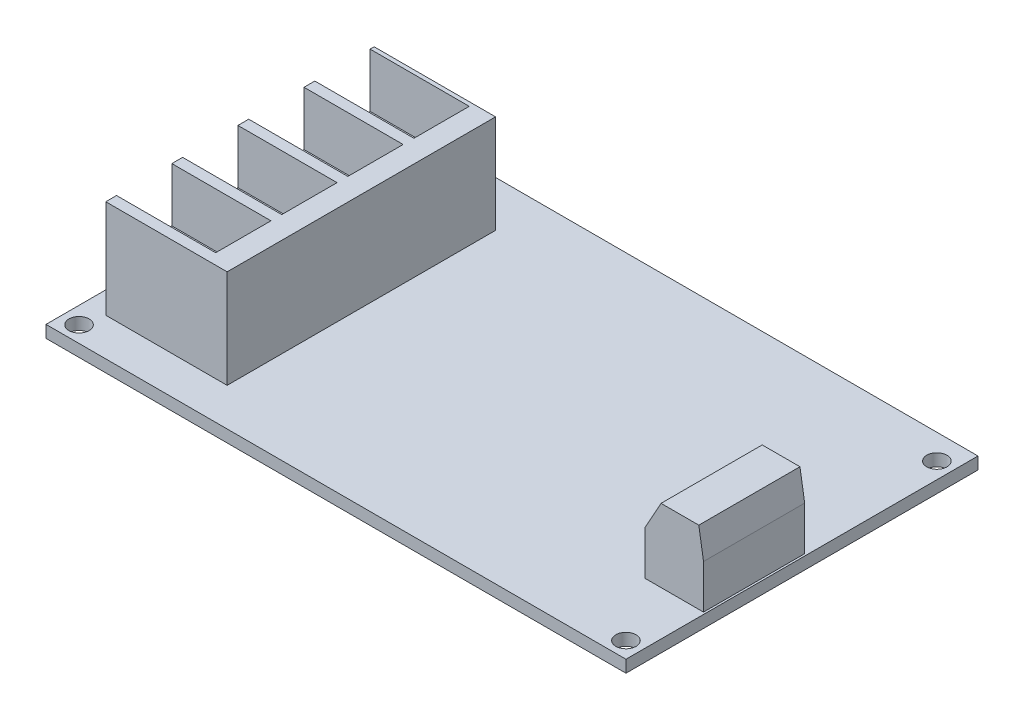
from build123d import *

# Parameters (mm, degrees)
SKETCH1_W           = 86
SKETCH1_H           = 52.2
BOSS_EXTRUDE1_DEPTH = 1.8
SKETCH3_R           = 1.5
CUT_EXTRUDE1_DEPTH  = 1.8
SKETCH4_W           = 8.7
SKETCH4_H           = 15
BOSS_EXTRUDE2_DEPTH = 6.5
SKETCH5_W           = 5.6
SKETCH5_H           = 15
BOSS_EXTRUDE3_DEPTH = 4.32
RIB11_REACH         = 94.939
SKETCH7_WALL_W      = 192.82008193
SKETCH7_WALL_H      = 15
RIB14_REACH         = 94.939
SKETCH8_WALL_W      = 192.25452497
SKETCH8_WALL_H      = 15
SKETCH9_W           = 18
SKETCH9_H           = 39.8
BOSS_EXTRUDE4_DEPTH = 14.58
SKETCH10_W          = 14.7
SKETCH10_H          = 8.2
CUT_EXTRUDE2_DEPTH  = 8


with BuildPart() as part:
    # Sketch1 → Boss-Extrude1 (new body)
    with BuildSketch(Plane(origin=(0, 0, 0), x_dir=(1, 0, 0), z_dir=(0, 1, 0))):
        with Locations((43, 26.1)):
            Rectangle(SKETCH1_W, SKETCH1_H)
    extrude(amount=BOSS_EXTRUDE1_DEPTH)

    # Sketch3 → Cut-Extrude1 (cut)
    with BuildSketch(Plane(origin=(0, 1.8, 0), x_dir=(1, 0, 0), z_dir=(0, 1, 0))):
        with Locations(Location((83.6, 2.4, 0), (0, 0, 270))):
            Circle(SKETCH3_R)
        with Locations(Location((83.6, 48.5, 0), (0, 0, 270))):
            Circle(SKETCH3_R)
        with Locations(Location((2.5, 2.4, 0), (0, 0, 270))):
            Circle(SKETCH3_R)
        with Locations(Location((2.5, 48.5, 0), (0, 0, 270))):
            Circle(SKETCH3_R)
    extrude(amount=-CUT_EXTRUDE1_DEPTH, mode=Mode.SUBTRACT)


with BuildPart() as body_2:
    # Sketch4 → Boss-Extrude2 (new body)
    with BuildSketch(Plane(origin=(0, 1.8, 0), x_dir=(1, 0, 0), z_dir=(0, 1, 0))):
        with Locations((81.35, 19.3)):
            Rectangle(SKETCH4_W, SKETCH4_H)
    extrude(amount=BOSS_EXTRUDE2_DEPTH)

    # Sketch5 → Boss-Extrude3 (add)
    with BuildSketch(Plane(origin=(0, 8.3, 0), x_dir=(1, 0, 0), z_dir=(0, 1, 0))):
        with Locations((82.2, 19.3)):
            Rectangle(SKETCH5_W, SKETCH5_H)
    extrude(amount=BOSS_EXTRUDE3_DEPTH)

    # Sketch7 wall → Rib11 (add, up to next)
    with BuildSketch(Plane(origin=(78.2, 10.46, -19.3), x_dir=(-0.485642931179, -0.874157276122, 0), z_dir=(0.874157276122, -0.485642931179, 0)), mode=Mode.PRIVATE) as rib11_sk1:
        Rectangle(SKETCH7_WALL_W, SKETCH7_WALL_H)
    rib11_tool1 = extrude(rib11_sk1.sketch, amount=RIB11_REACH, mode=Mode.PRIVATE) - body_2.part
    add(rib11_tool1.solids().sort_by_distance((78.2, 10.46, -19.3))[0])

    # Sketch8 wall → Rib14 (add, up to next)
    with BuildSketch(Plane(origin=(85.35, 10.46, -19.3), x_dir=(0.159950808002, -0.987124986524, 0), z_dir=(0.987124986524, 0.159950808002, 0)), mode=Mode.PRIVATE) as rib14_sk1:
        Rectangle(SKETCH8_WALL_W, SKETCH8_WALL_H)
    rib14_tool1 = extrude(rib14_sk1.sketch, amount=-RIB14_REACH, mode=Mode.PRIVATE) - body_2.part
    add(rib14_tool1.solids().sort_by_distance((85.35, 10.46, -19.3))[0])


with BuildPart() as body_3:
    # Sketch9 → Boss-Extrude4 (new body)
    with BuildSketch(Plane(origin=(0, 1.8, 0), x_dir=(1, 0, 0), z_dir=(0, 1, 0))):
        with Locations((12.26, 25.5)):
            Rectangle(SKETCH9_W, SKETCH9_H)
    extrude(amount=BOSS_EXTRUDE4_DEPTH)

    # Sketch10 → Cut-Extrude2 (cut)
    with BuildSketch(Plane(origin=(0, 16.38, 0), x_dir=(1, 0, 0), z_dir=(0, 1, 0))):
        with Locations((10.61, 11.3)):
            Rectangle(SKETCH10_W, SKETCH10_H)
        with Locations((10.61, 21.1)):
            Rectangle(SKETCH10_W, SKETCH10_H)
        with Locations((10.61, 30.9)):
            Rectangle(SKETCH10_W, SKETCH10_H)
        with Locations((10.61, 40.7)):
            Rectangle(SKETCH10_W, SKETCH10_H)
    extrude(amount=-CUT_EXTRUDE2_DEPTH, mode=Mode.SUBTRACT)


solid = Compound([part.part, body_2.part, body_3.part])
